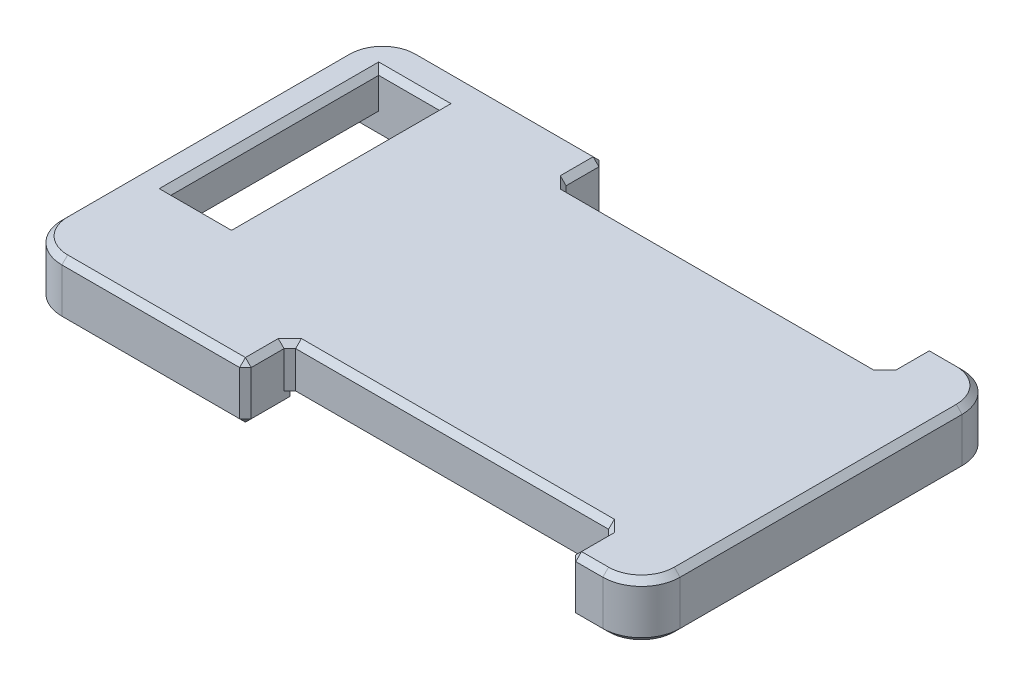
from build123d import *

# Parameters (mm, degrees)
SKETCH_1_W          = 32
SKETCH_1_H          = 18.6
EXTRUDE_1_DEPTH     = 2.2
FILLET_1_R          = 2
SKETCH_2_W          = 3.14
SKETCH_2_H          = 10.76
SKETCH_2_W_2        = 16.8
SKETCH_2_H_2        = 2.6
CUT_EXTRUDE_1_DEPTH = 3.2
EXTRUDE_2_DEPTH     = 0.7
CHAMFER_1_SIZE      = 0.3
CHAMFER_2_SIZE      = 1


with BuildPart() as part:
    # 草图1 → 凸台-拉伸1 (new body)
    with BuildSketch(Plane(origin=(0, 0, 0), x_dir=(1, 0, 0), z_dir=(0, 1, 0))):
        with Locations((47.27991, 9.3)):
            Rectangle(SKETCH_1_W, SKETCH_1_H)
    extrude(amount=EXTRUDE_1_DEPTH)

    # 圆角1
    fillet_1_edges = [part.edges().sort_by_distance(p)[0] for p in [
        (31.27991, 1.1, -18.6),
        (63.27991, 1.1, -18.6),
        (63.27991, 1.1, 0),
        (31.27991, 1.1, 0),
    ]]
    fillet(fillet_1_edges, radius=FILLET_1_R)

    # 草图2 → 切除-拉伸1 (cut, through all)
    with BuildSketch(Plane(origin=(0, 2.2, 0), x_dir=(1, 0, 0), z_dir=(0, 1, 0))):
        with Locations((34.54991, 11.32)):
            Rectangle(SKETCH_2_W, SKETCH_2_H)
        with Locations((51.17991, 1)):
            Rectangle(SKETCH_2_W_2, SKETCH_2_H_2)
        with Locations((51.17991, 17.6)):
            Rectangle(SKETCH_2_W_2, SKETCH_2_H_2)
    extrude(amount=-CUT_EXTRUDE_1_DEPTH, mode=Mode.SUBTRACT)

    # 草图3 → 凸台-拉伸2 (add)
    with BuildSketch(Plane.XZ):
        with BuildLine():
            Line((36.11991, -5.94), (36.11991, -2.3))
            Line((36.11991, -2.3), (42.77991, -2.3))
            Line((42.77991, -2.3), (42.77991, 0))
            Line((42.77991, 0), (33.27991, 0))
            ThreePointArc((33.27991, 0), (31.865696, -0.585786), (31.27991, -2))
            Line((31.27991, -2), (31.27991, -16.6))
            ThreePointArc((31.27991, -16.6), (31.865696, -18.014214), (33.27991, -18.6))
            Line((33.27991, -18.6), (42.77991, -18.6))
            Line((42.77991, -18.6), (42.77991, -16.3))
            Line((42.77991, -16.3), (36.11991, -16.3))
            Line((36.11991, -16.3), (36.11991, -16.7))
            Line((36.11991, -16.7), (32.97991, -16.7))
            Line((32.97991, -16.7), (32.97991, -5.94))
            Line((32.97991, -5.94), (36.11991, -5.94))
        make_face()
        with BuildLine():
            Line((59.57991, -16.3), (59.57991, -18.6))
            Line((59.57991, -18.6), (61.27991, -18.6))
            ThreePointArc((61.27991, -18.6), (62.694123, -18.014214), (63.27991, -16.6))
            Line((63.27991, -16.6), (63.27991, -2))
            ThreePointArc((63.27991, -2), (62.694123, -0.585786), (61.27991, 0))
            Line((61.27991, 0), (59.57991, 0))
            Line((59.57991, 0), (59.57991, -2.3))
            Line((59.57991, -2.3), (59.57991, -16.3))
        make_face()
    extrude(amount=EXTRUDE_2_DEPTH)

    # 倒角1
    chamfer_1_edges = [part.edges().sort_by_distance(p)[0] for p in [
        (36.11991, -0.7, -4.12),
        (34.54991, -0.7, -5.94),
        (39.44991, -0.7, -16.3),
        (42.77991, -0.7, -17.45),
        (38.02991, -0.7, -18.6),
        (31.865696, -0.7, -18.014214),
        (31.27991, -0.7, -9.3),
        (31.865696, -0.7, -0.585786),
        (38.02991, -0.7, 0),
        (42.77991, -0.7, -1.15),
        (39.44991, -0.7, -2.3),
        (60.42991, -0.7, 0),
        (62.694123, -0.7, -0.585786),
        (63.27991, -0.7, -9.3),
        (62.694123, -0.7, -18.014214),
        (60.42991, -0.7, -18.6),
        (59.57991, -0.7, -9.3),
        (38.02991, 2.2, 0),
        (31.865696, 2.2, -0.585786),
        (31.27991, 2.2, -9.3),
        (31.865696, 2.2, -18.014214),
        (38.02991, 2.2, -18.6),
        (42.77991, 2.2, -17.45),
        (51.17991, 2.2, -16.3),
        (59.57991, 2.2, -17.45),
        (60.42991, 2.2, -18.6),
        (62.694123, 2.2, -18.014214),
        (63.27991, 2.2, -9.3),
        (62.694123, 2.2, -0.585786),
        (60.42991, 2.2, 0),
        (59.57991, 2.2, -1.15),
        (51.17991, 2.2, -2.3),
        (42.77991, 2.2, -1.15),
        (34.54991, 2.2, -16.7),
        (32.97991, 2.2, -11.32),
        (34.54991, 2.2, -5.94),
        (36.11991, 2.2, -11.32),
        (42.77991, 0.75, -18.6),
        (42.77991, 1.1, -16.3),
        (59.57991, 1.1, -16.3),
        (59.57991, 0.75, -18.6),
        (59.57991, 0.75, 0),
        (59.57991, 1.1, -2.3),
        (42.77991, 1.1, -2.3),
        (42.77991, 0.75, 0),
    ]]
    chamfer(chamfer_1_edges, length=CHAMFER_1_SIZE)

    # 倒角2
    chamfer_2_edges = [part.edges().sort_by_distance(p)[0] for p in [
        (32.97991, -0.7, -11.32),
    ]]
    chamfer(chamfer_2_edges, length=CHAMFER_2_SIZE)


solid = part.part
